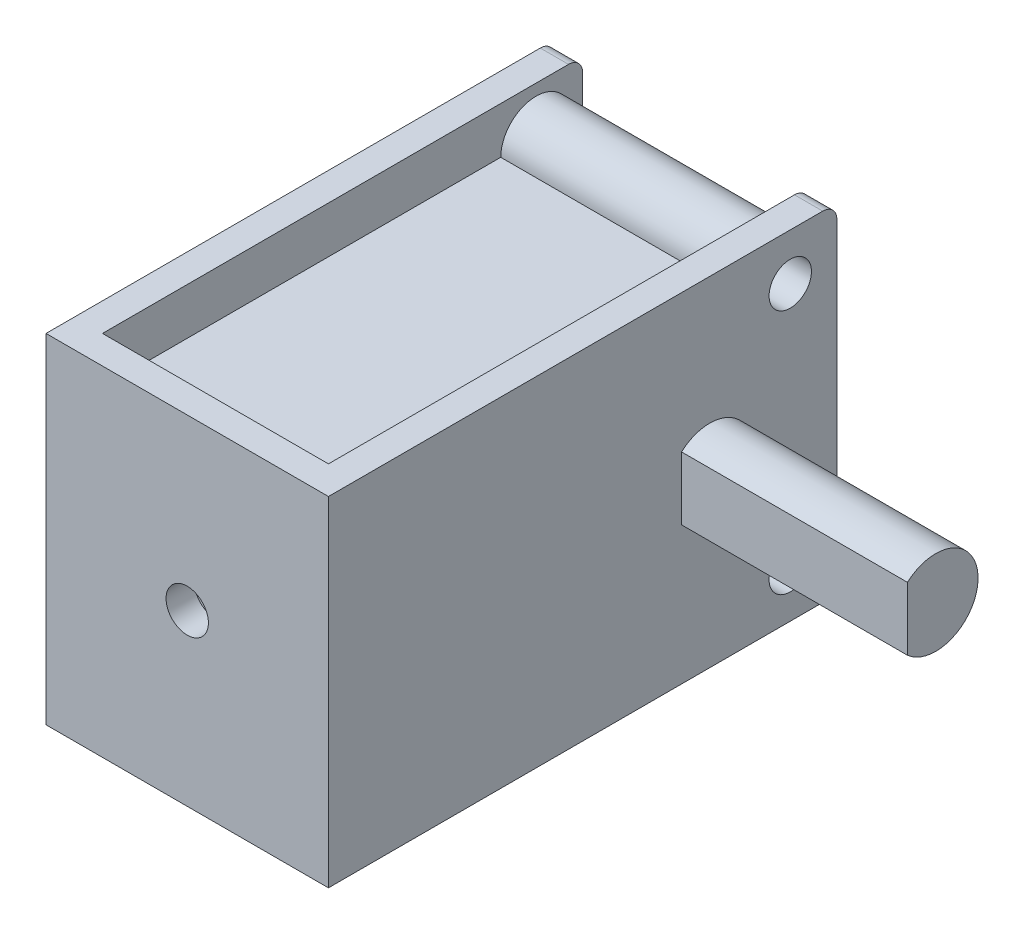
from build123d import *

# Parameters (mm, degrees)
ESBO_O1_W                = 10
ESBO_O1_H                = 18
RESSALTO_EXTRUS_O1_DEPTH = 6
RESSALTO_EXTRUS_O2_DEPTH = 8
FILETE1_R                = 0.5
ESBO_O3_W                = 8
ESBO_O3_H                = 17
CORTE_EXTRUS_O1_DEPTH    = 13
RESSALTO_EXTRUS_O3_REACH = 12
ESBO_O4_R                = 1.25
ESBO_O5_R                = 0.75
CORTE_EXTRUS_O2_DEPTH    = 11
CORTE_EXTRUS_O3_REACH    = 20
ESBO_O6_R                = 0.75
RESSALTO_EXTRUS_O6_REACH = 19
ESBO_O7_W                = 14.6
ESBO_O7_H                = 8.7


with BuildPart() as part:
    # Esboço1 → Ressalto-extrusão1 (new body, symmetric)
    with BuildSketch(Plane(origin=(0, 0, 0), x_dir=(1, 0, 0), z_dir=(0, 1, 0))):
        Rectangle(ESBO_O1_W, ESBO_O1_H)
    extrude(amount=RESSALTO_EXTRUS_O1_DEPTH, both=True)

    # Esboço2 → Ressalto-extrusão2 (add)
    with BuildSketch(Plane(origin=(5, 0, 0), x_dir=(0, 0, -1), z_dir=(1, 0, 0))):
        with BuildLine():
            Line((3.5, 1.118033989), (3.5, -1.118033989))
            ThreePointArc((3.5, -1.118033989), (6, 0), (3.5, 1.118033989))
        make_face()
    extrude(amount=RESSALTO_EXTRUS_O2_DEPTH)

    # Filete1
    filete1_edges = [part.edges().sort_by_distance(p)[0] for p in [
        (0, -6, -9),
        (0, 6, -9),
    ]]
    fillet(filete1_edges, radius=FILETE1_R)

    # Esboço3 → Corte-extrusão1 (cut, through all)
    with BuildSketch(Plane(origin=(0, 6, 0), x_dir=(1, 0, 0), z_dir=(0, 1, 0))):
        with Locations((0, 0.5)):
            Rectangle(ESBO_O3_W, ESBO_O3_H)
    extrude(amount=-CORTE_EXTRUS_O1_DEPTH, mode=Mode.SUBTRACT)

    # Esboço4 → Ressalto-extrusão3 (add, up to next)
    with BuildSketch(Plane(origin=(5, 0, 0), x_dir=(0, 0, -1), z_dir=(1, 0, 0)), mode=Mode.PRIVATE) as ressalto_extrus_o3_sk1:
        with Locations((7.35, 4.35)):
            Circle(ESBO_O4_R)
    ressalto_extrus_o3_tool1 = extrude(ressalto_extrus_o3_sk1.sketch, amount=-RESSALTO_EXTRUS_O3_REACH, mode=Mode.PRIVATE) - part.part
    add(ressalto_extrus_o3_tool1.solids().sort_by_distance((5, 4.35, -7.35))[0])
    # Esboço4 → Ressalto-extrusão3 (add, up to next)
    with BuildSketch(Plane(origin=(5, 0, 0), x_dir=(0, 0, -1), z_dir=(1, 0, 0)), mode=Mode.PRIVATE) as ressalto_extrus_o3_sk2:
        with Locations((7.35, -4.35)):
            Circle(ESBO_O4_R)
    ressalto_extrus_o3_tool2 = extrude(ressalto_extrus_o3_sk2.sketch, amount=-RESSALTO_EXTRUS_O3_REACH, mode=Mode.PRIVATE) - part.part
    add(ressalto_extrus_o3_tool2.solids().sort_by_distance((5, -4.35, -7.35))[0])

    # Esboço5 → Corte-extrusão2 (cut, through all)
    with BuildSketch(Plane(origin=(5, 0, 0), x_dir=(0, 0, -1), z_dir=(1, 0, 0))):
        with Locations((7.35, 4.35)):
            Circle(ESBO_O5_R)
        with Locations((7.35, -4.35)):
            Circle(ESBO_O5_R)
    extrude(amount=-CORTE_EXTRUS_O2_DEPTH, mode=Mode.SUBTRACT)

    # Esboço6 → Corte-extrusão3 (cut, up to next)
    with BuildSketch(Plane.XY.offset(9), mode=Mode.PRIVATE) as corte_extrus_o3_sk1:
        Circle(ESBO_O6_R)
    corte_extrus_o3_tool1 = extrude(corte_extrus_o3_sk1.sketch, amount=-CORTE_EXTRUS_O3_REACH, mode=Mode.PRIVATE) & part.part
    add(corte_extrus_o3_tool1.solids().sort_by_distance((0, 0, 9))[0], mode=Mode.SUBTRACT)

    # Esboço7 → Ressalto-extrusão6 (add, up to next)
    with BuildSketch(Plane(origin=(-4, 0, 0), x_dir=(0, 0, -1), z_dir=(1, 0, 0)), mode=Mode.PRIVATE) as ressalto_extrus_o6_sk1:
        with Locations((-0.7, 0)):
            Rectangle(ESBO_O7_W, ESBO_O7_H)
    ressalto_extrus_o6_tool1 = extrude(ressalto_extrus_o6_sk1.sketch, amount=RESSALTO_EXTRUS_O6_REACH, mode=Mode.PRIVATE) - part.part
    add(ressalto_extrus_o6_tool1.solids().sort_by_distance((-4, 0, 0.7))[0])


solid = part.part
